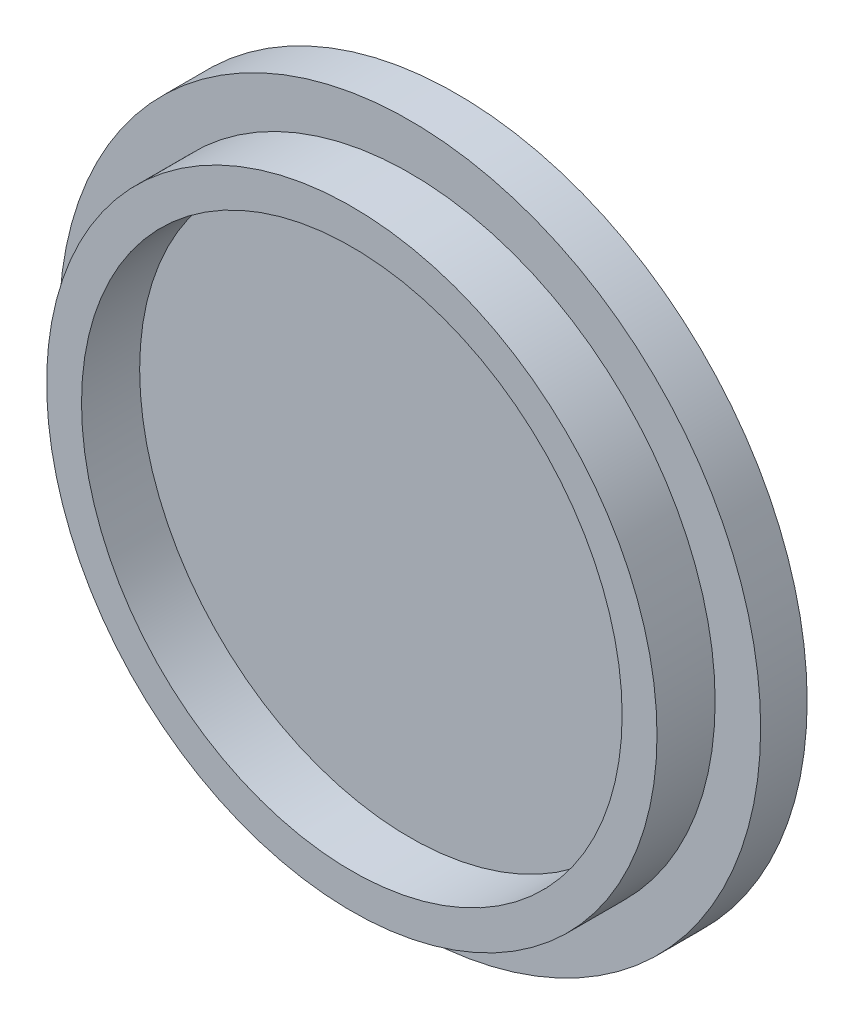
from build123d import *

# Parameters (mm, degrees)
SALIENTE_EXTRUIR1_DEPTH      = 2
SALIENTE_EXTRUIR1_DEPTH_BACK = 2
CROQUIS1_R                   = 30.165
CROQUIS3_R                   = 26.25
CROQUIS3_R_2                 = 23.25
SALIENTE_EXTRUIR2_DEPTH      = 5


with BuildPart() as part:
    # Croquis1 → Saliente-Extruir1 (new, two sides: drawn at the far end of the back side and taken through both)
    with BuildSketch(Plane.XY.offset(-SALIENTE_EXTRUIR1_DEPTH_BACK)):
        Circle(CROQUIS1_R)
    extrude(amount=SALIENTE_EXTRUIR1_DEPTH + SALIENTE_EXTRUIR1_DEPTH_BACK)

    # Croquis3 → Saliente-Extruir2 (add)
    with BuildSketch(Plane.XY.offset(2)):
        Circle(CROQUIS3_R)
        Circle(CROQUIS3_R_2, mode=Mode.SUBTRACT)
    extrude(amount=SALIENTE_EXTRUIR2_DEPTH)


solid = part.part
